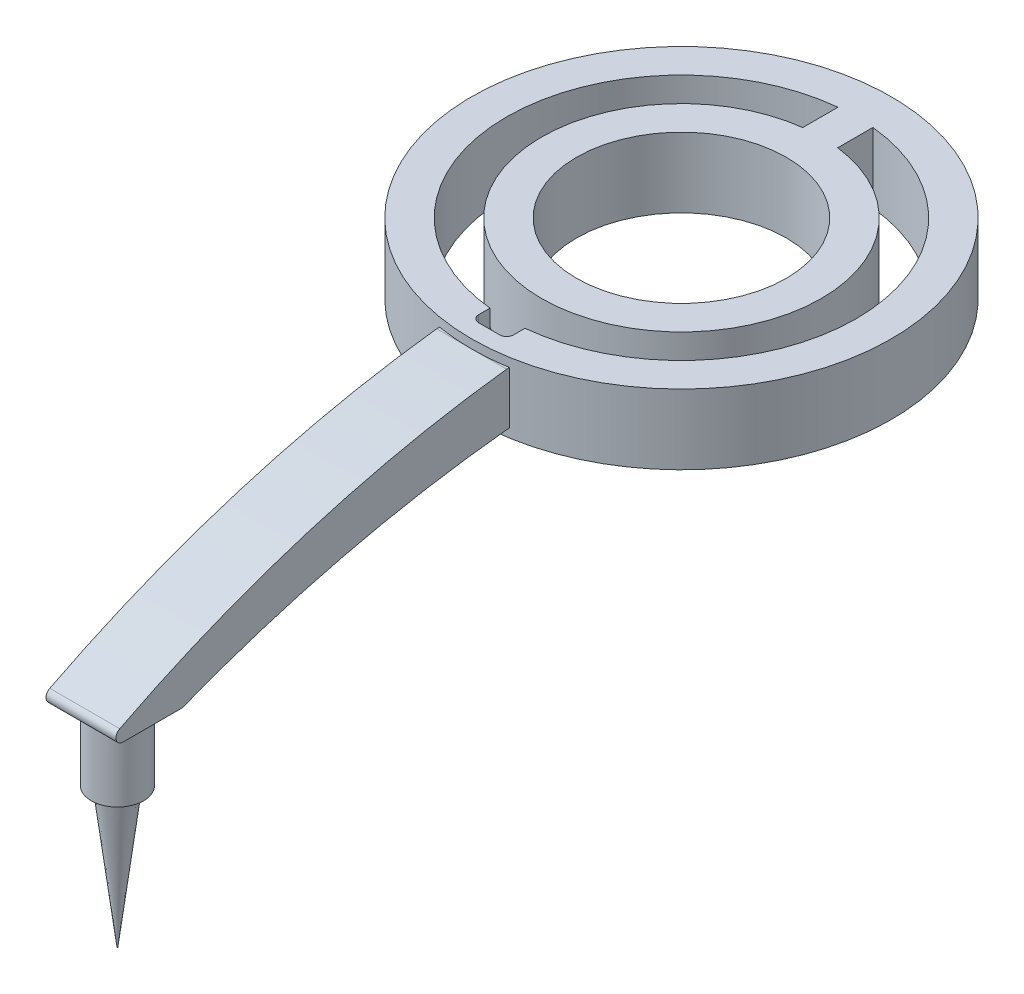
from build123d import *

# Parameters (mm, degrees)
SKETCH1_R           = 30
SKETCH1_R_2         = 15
BOSS_EXTRUDE1_DEPTH = 10
BOSS_EXTRUDE2_DEPTH = 5
SKETCH3_R           = 3.75
BOSS_EXTRUDE3_DEPTH = 10
SKETCH5_R           = 2.5
BOSS_EXTRUDE4_DEPTH = 20
BOSS_EXTRUDE4_TAPER = 7


with BuildPart() as part:
    # Sketch1 → Boss-Extrude1 (new body)
    with BuildSketch(Plane(origin=(0, 0, 0), x_dir=(1, 0, 0), z_dir=(0, 1, 0))):
        Circle(SKETCH1_R)
        with BuildLine():
            ThreePointArc((-2.5, -24.874685928), (-25, 0), (-2.5, 24.874685928))
            Line((-2.5, 24.874685928), (-2.5, 19.843134833))
            ThreePointArc((-2.5, 19.843134833), (0, -20), (2.5, 19.843134833))
            Line((2.5, 19.843134833), (2.5, 24.874685928))
            ThreePointArc((2.5, 24.874685928), (25, 0), (2.5, -24.874685928))
            Line((2.5, -24.874685928), (2.5, -26.5))
            ThreePointArc((2.5, -26.5), (2.207106781, -27.207106781), (1.5, -27.5))
            Line((1.5, -27.5), (-1.5, -27.5))
            ThreePointArc((-1.5, -27.5), (-2.207106781, -27.207106781), (-2.5, -26.5))
            Line((-2.5, -26.5), (-2.5, -24.874685928))
        make_face(mode=Mode.SUBTRACT)
        Circle(SKETCH1_R_2, mode=Mode.SUBTRACT)
    extrude(amount=BOSS_EXTRUDE1_DEPTH)

    # Sketch2 → Boss-Extrude2 (add, symmetric)
    with BuildSketch(Plane(origin=(0, 0, 0), x_dir=(0, 0, -1), z_dir=(1, 0, 0))):
        with BuildLine():
            Line((-84.861603584, -10), (-76.4, -10))
            ThreePointArc((-76.4, -10), (-53.579230072, -2.810886638), (-30, 1.25))
            Line((-30, 1.25), (-27.5, 1.25))
            Line((-27.5, 1.25), (-27.5, 8.75))
            Line((-27.5, 8.75), (-30, 8.75))
            ThreePointArc((-30, 8.75), (-58.40777346, 2.778023012), (-85.317259729, -8.109844128))
            ThreePointArc((-85.317259729, -8.109844128), (-85.833754774, -9.234354569), (-84.861603584, -10))
        make_face()
    extrude(amount=BOSS_EXTRUDE2_DEPTH, both=True)

    # Sketch3 → Boss-Extrude3 (add)
    with BuildSketch(Plane(origin=(0, -10, 0), x_dir=(-1, 0, 0), z_dir=(0, -1, 0))):
        with Locations((0, -80.65)):
            Circle(SKETCH3_R)
    extrude(amount=BOSS_EXTRUDE3_DEPTH)

    # Sketch5 → Boss-Extrude4 (add)
    with BuildSketch(Plane(origin=(0, -20, 0), x_dir=(-1, 0, 0), z_dir=(0, -1, 0))):
        with Locations((0, -80.65)):
            Circle(SKETCH5_R)
    extrude(amount=BOSS_EXTRUDE4_DEPTH, taper=BOSS_EXTRUDE4_TAPER)


solid = part.part
